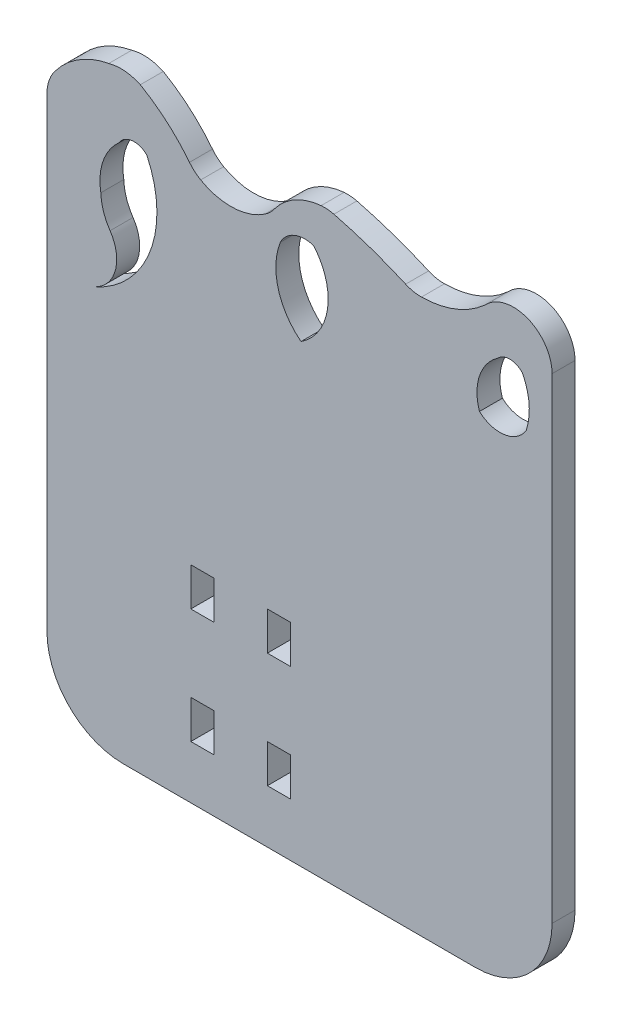
from build123d import *

# Parameters (mm, degrees)
MODEL_W                 = 3
MODEL_H                 = 5
SALIENTE_EXTRUIR1_DEPTH = 3


with BuildPart() as part:
    # Model → Saliente-Extruir1 (new body)
    with BuildSketch(Plane.XY):
        with BuildLine():
            Line((25.823008531, 25.328827472), (25.823008531, -27.332866004))
            ThreePointArc((25.823008531, -27.332866004), (28.747771663, -34.399762301), (35.811213184, -37.332859048))
            Line((35.811213184, -37.332859048), (81.813268997, -37.378641912))
            ThreePointArc((81.813268997, -37.378641912), (88.89063275, -34.453157454), (91.823009601, -27.378646656))
            Line((91.823009601, -27.378646656), (91.823009601, 34.821697163))
            ThreePointArc((91.823009601, 34.821697163), (88.685239194, 39.45821871), (83.197638532, 38.349537442))
            ThreePointArc((83.197638532, 38.349537442), (83.091891778, 38.246548616), (82.983150977, 38.146726212))
            ThreePointArc((82.983150977, 38.146726212), (79.158392414, 35.809046345), (74.756507073, 34.962328761))
            ThreePointArc((74.756507073, 34.962328761), (73.700057315, 35.063620335), (72.68878473, 35.38560455))
            ThreePointArc((72.68878473, 35.38560455), (68.069225879, 37.194690132), (63.316100845, 38.616279747))
            ThreePointArc((63.316100845, 38.616279747), (62.485957107, 38.754544477), (61.644382862, 38.751619998))
            ThreePointArc((61.644382862, 38.751619998), (58.215145594, 37.688534886), (55.531115502, 35.304043186))
            ThreePointArc((55.531115502, 35.304043186), (54.958944511, 34.649794571), (54.282120522, 34.104514662))
            ThreePointArc((54.282120522, 34.104514662), (50.140040935, 32.758182229), (45.908966143, 33.791352311))
            ThreePointArc((45.908966143, 33.791352311), (45.116243353, 34.349525285), (44.446145174, 35.050192768))
            ThreePointArc((44.446145174, 35.050192768), (41.500295, 38.141911881), (38.022338936, 40.619931641))
            ThreePointArc((38.022338936, 40.619931641), (35.993879777, 41.16016146), (33.903505077, 40.96825411))
            ThreePointArc((33.903505077, 40.96825411), (29.987740451, 39.437981004), (26.890761417, 36.594801579))
            ThreePointArc((26.890761417, 36.594801579), (26.097480223, 35.140352586), (25.823008531, 33.506528172))
            Line((25.823008531, 33.506528172), (25.823008531, 25.328827472))
        make_face()
        with Locations((56.123009601, -12.898202125)):
            Rectangle(MODEL_W, MODEL_H, mode=Mode.SUBTRACT)
        with Locations((46.123009601, -12.898202125)):
            Rectangle(MODEL_W, MODEL_H, mode=Mode.SUBTRACT)
        with Locations((56.123009601, -27.898202125)):
            Rectangle(MODEL_W, MODEL_H, mode=Mode.SUBTRACT)
        with Locations((46.123009601, -27.898202125)):
            Rectangle(MODEL_W, MODEL_H, mode=Mode.SUBTRACT)
        with BuildLine():
            ThreePointArc((31.891647008, 14.698529627), (34.737479764, 17.894903167), (34.068174805, 22.121911417))
            ThreePointArc((34.068174805, 22.121911417), (33.201238031, 23.883836719), (32.862791652, 25.818110274))
            ThreePointArc((32.862791652, 25.818110274), (33.159875497, 29.564217988), (35.254372097, 32.684260585))
            ThreePointArc((35.254372097, 32.684260585), (36.97332261, 33.76093452), (38.880316643, 33.069999366))
            ThreePointArc((38.880316643, 33.069999366), (39.303180243, 22.39412756), (31.891647008, 14.698529627))
        make_face(mode=Mode.SUBTRACT)
        with BuildLine():
            ThreePointArc((60.669464902, 33.72846753), (58.153624192, 33.64814712), (56.308435323, 31.936077063))
            ThreePointArc((56.308435323, 31.936077063), (56.034810359, 26.550644681), (59.015292929, 22.056818226))
            ThreePointArc((59.015292929, 22.056818226), (62.490702694, 27.517307494), (60.669464902, 33.72846753))
        make_face(mode=Mode.SUBTRACT)
        with BuildLine():
            ThreePointArc((87.974912144, 32.931323036), (86.39007686, 33.704958001), (84.750501033, 33.055338848))
            ThreePointArc((84.750501033, 33.055338848), (82.332342702, 29.830877737), (82.3321927, 25.800413849))
            ThreePointArc((82.3321927, 25.800413849), (85.598214893, 24.80893095), (88.439971438, 26.699528486))
            ThreePointArc((88.439971438, 26.699528486), (88.820060436, 29.86114357), (87.974912144, 32.931323036))
        make_face(mode=Mode.SUBTRACT)
    extrude(amount=SALIENTE_EXTRUIR1_DEPTH)


solid = part.part
